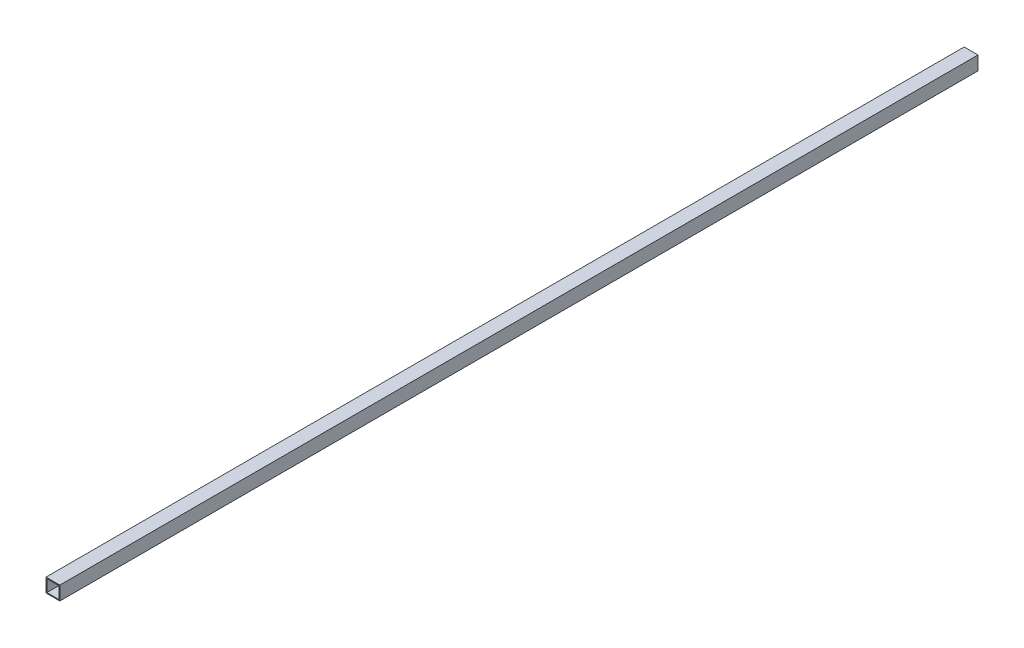
from build123d import *

# Parameters (mm, degrees)
SKETCH1_W           = 30
SKETCH1_H           = 30
SKETCH1_W_2         = 26
SKETCH1_H_2         = 26
BOSS_EXTRUDE1_DEPTH = 996


with BuildPart() as part:
    # Sketch1 → Boss-Extrude1 (new body, symmetric)
    with BuildSketch(Plane.XY):
        Rectangle(SKETCH1_W, SKETCH1_H)
        Rectangle(SKETCH1_W_2, SKETCH1_H_2, mode=Mode.SUBTRACT)
    extrude(amount=BOSS_EXTRUDE1_DEPTH, both=True)


solid = part.part
